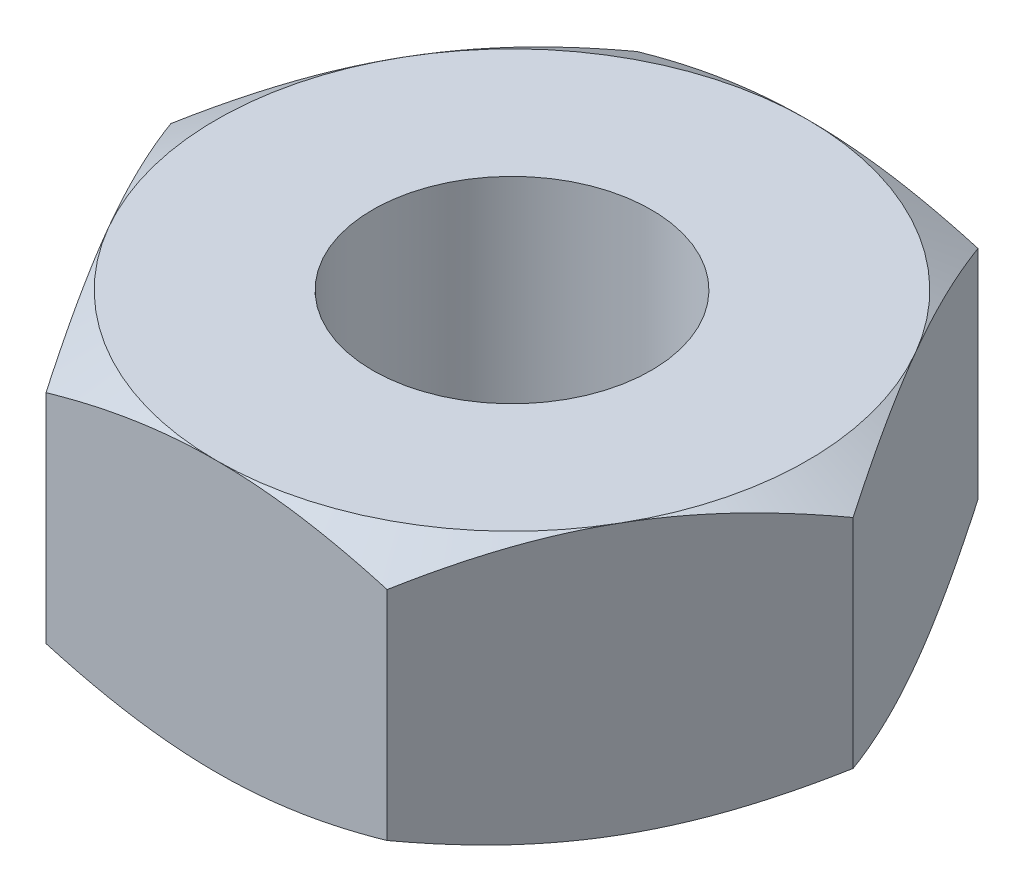
from build123d import *

# Parameters (mm, degrees)
BOSS_EXTRUDE1_DEPTH = 3.2
M4_TAPPED_HOLE1_D   = 3.3


with BuildPart() as part:
    # Sketch1 → Boss-Extrude1 (new body)
    with BuildSketch(Plane(origin=(0, 0, 0), x_dir=(1, 0, 0), z_dir=(0, 1, 0))):
        Polygon((-2.020725942, -3.5), (2.020725942, -3.5), (4.041451884, 0), (2.020725942, 3.5), (-2.020725942, 3.5), (-4.041451884, 0), align=None)
    extrude(amount=BOSS_EXTRUDE1_DEPTH)

    # Sketch2 → Cut-Revolve1 (revolve, cut)
    with BuildSketch(Plane(origin=(0, 0, 0), x_dir=(0, 0, -1), z_dir=(1, 0, 0))):
        Polygon((5.627238375, 1.228161648), (3.5, 0), (5.627238375, 0), align=None)
        Polygon((3.5, 3.2), (5.644714185, 3.2), (5.644714185, 1.961748688), align=None)
    revolve(axis=Axis((0, 0, 0), (0, 1, 0)), mode=Mode.SUBTRACT)

    # M4 Tapped Hole1 (through all)
    with Locations(Plane.ZX.offset(3.2)):
        with Locations((0, 0)):
            Hole(M4_TAPPED_HOLE1_D / 2)


solid = part.part
